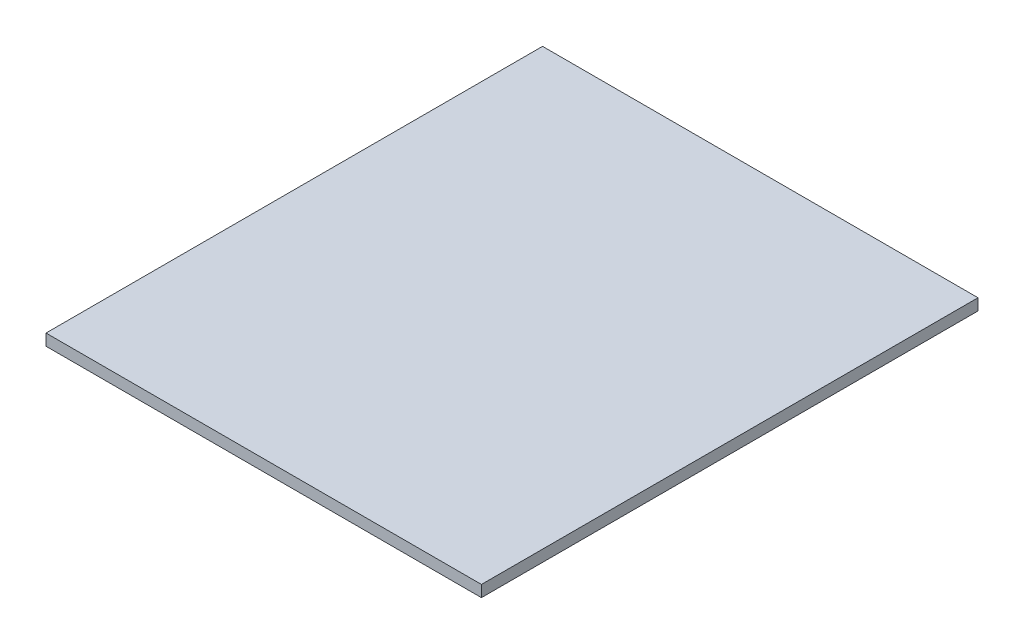
from build123d import *

# Parameters (mm, degrees)
SKETCH1_W           = 114
SKETCH1_H           = 130
BOSS_EXTRUDE1_DEPTH = 3


with BuildPart() as part:
    # Sketch1 → Boss-Extrude1 (new body)
    with BuildSketch(Plane(origin=(0, 0, 0), x_dir=(1, 0, 0), z_dir=(0, 1, 0))):
        with Locations((-237, -52)):
            Rectangle(SKETCH1_W, SKETCH1_H)
    extrude(amount=BOSS_EXTRUDE1_DEPTH)


solid = part.part
